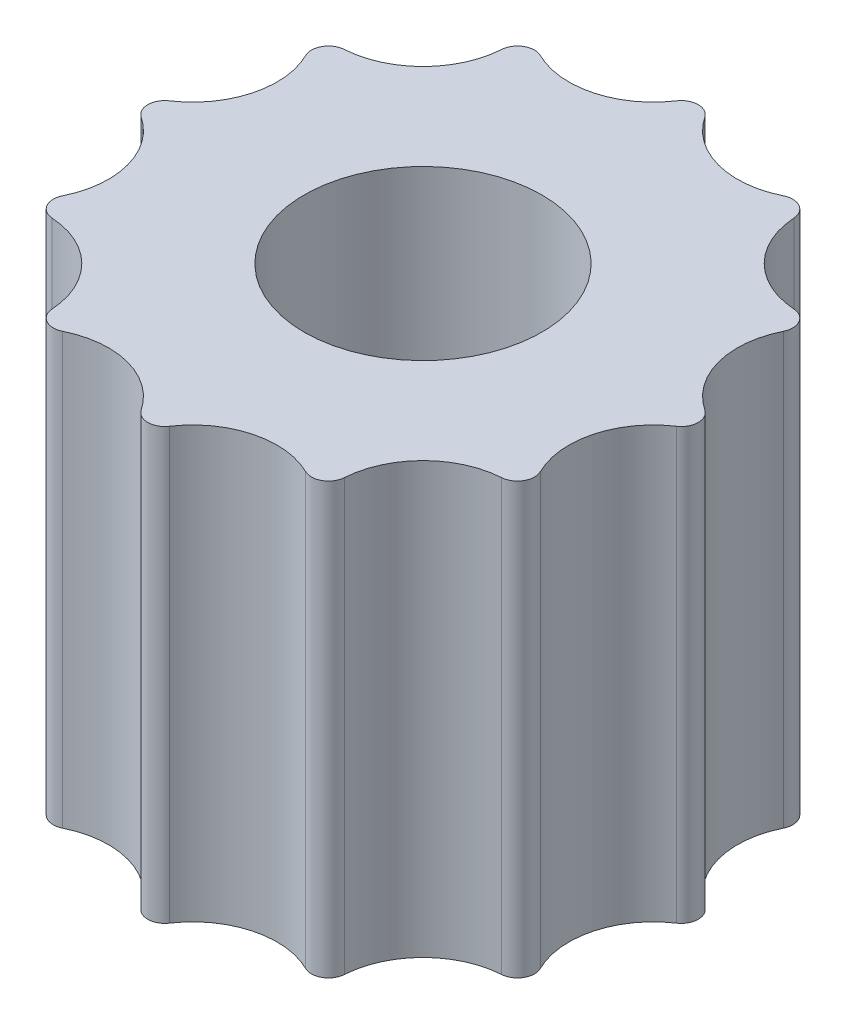
from build123d import *

# Parameters (mm, degrees)
SKETCH_1_R      = 2.1
EXTRUDE_1_DEPTH = 7.6
FILLET_1_R      = 0.3


with BuildPart() as part:
    # 草图1 → 凸台-拉伸1 (new body)
    with BuildSketch(Plane(origin=(0, 0, 0), x_dir=(1, 0, 0), z_dir=(0, 1, 0))):
        with BuildLine():
            ThreePointArc((-2.75, 4.763139721), (-1.102778373, 4.115624918), (0, 5.5))
            ThreePointArc((0, 5.5), (1.102778373, 4.115624918), (2.75, 4.763139721))
            ThreePointArc((2.75, 4.763139721), (3.012846545, 3.012846545), (4.763139721, 2.75))
            ThreePointArc((4.763139721, 2.75), (4.115624918, 1.102778373), (5.5, 0))
            ThreePointArc((5.5, 0), (4.115624918, -1.102778373), (4.763139721, -2.75))
            ThreePointArc((4.763139721, -2.75), (3.012846545, -3.012846545), (2.75, -4.763139721))
            ThreePointArc((2.75, -4.763139721), (1.102778373, -4.115624918), (0, -5.5))
            ThreePointArc((0, -5.5), (-1.102778373, -4.115624918), (-2.75, -4.763139721))
            ThreePointArc((-2.75, -4.763139721), (-3.012846545, -3.012846545), (-4.763139721, -2.75))
            ThreePointArc((-4.763139721, -2.75), (-4.115624918, -1.102778373), (-5.5, 0))
            ThreePointArc((-5.5, 0), (-4.115624918, 1.102778373), (-4.763139721, 2.75))
            ThreePointArc((-4.763139721, 2.75), (-3.012846545, 3.012846545), (-2.75, 4.763139721))
        make_face()
        Circle(SKETCH_1_R, mode=Mode.SUBTRACT)
    extrude(amount=EXTRUDE_1_DEPTH)

    # 圆角1
    fillet_1_edges = [part.edges().sort_by_distance(p)[0] for p in [
        (-2.75, 3.8, -4.763139721),
        (0, 3.8, -5.5),
        (2.75, 3.8, -4.763139721),
        (4.763139721, 3.8, -2.75),
        (5.5, 3.8, 0),
        (4.763139721, 3.8, 2.75),
        (2.75, 3.8, 4.763139721),
        (0, 3.8, 5.5),
        (-2.75, 3.8, 4.763139721),
        (-4.763139721, 3.8, 2.75),
        (-5.5, 3.8, 0),
        (-4.763139721, 3.8, -2.75),
    ]]
    fillet(fillet_1_edges, radius=FILLET_1_R)


solid = part.part
